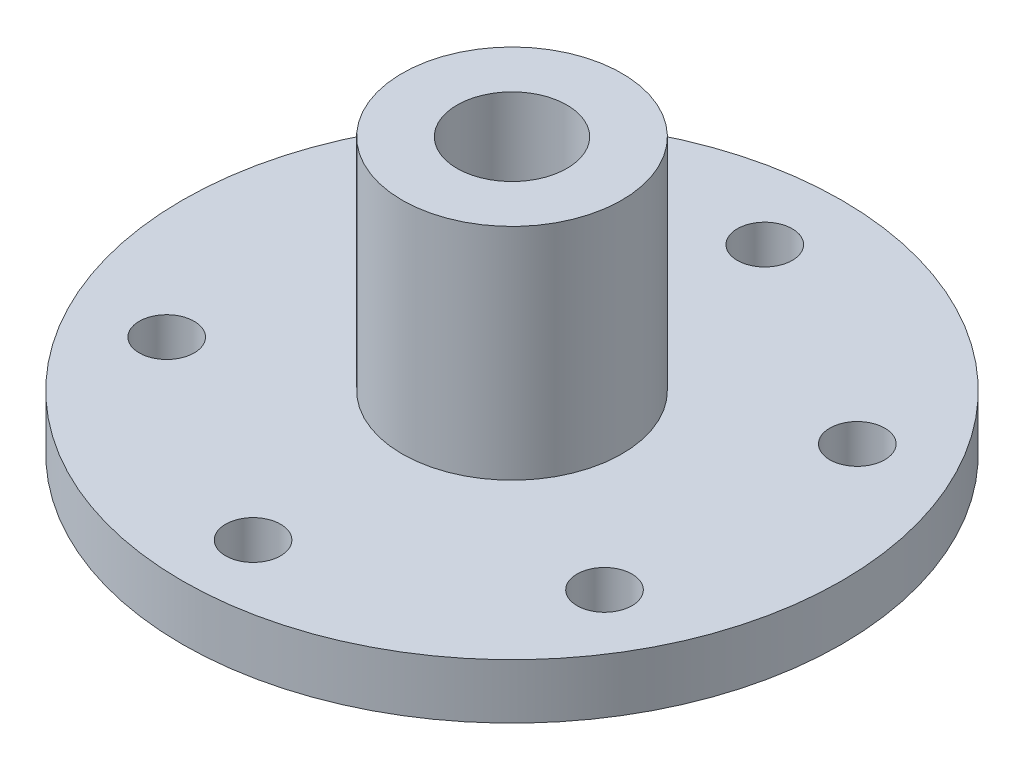
from build123d import *

# Parameters (mm, degrees)
SKETCH1_R           = 30
SKETCH1_R_2         = 2.5
BOSS_EXTRUDE2_DEPTH = 5
SKETCH2_R           = 10
BOSS_EXTRUDE3_DEPTH = 20
SKETCH3_R           = 5
CUT_EXTRUDE1_DEPTH  = 45


with BuildPart() as part:
    # Sketch1 → Boss-Extrude2 (new body)
    with BuildSketch(Plane(origin=(0, 0, 0), x_dir=(1, 0, 0), z_dir=(0, 1, 0))):
        Circle(SKETCH1_R)
        with Locations((0, 23)):
            Circle(SKETCH1_R_2, mode=Mode.SUBTRACT)
        with Locations((19.918584287, 11.5)):
            Circle(SKETCH1_R_2, mode=Mode.SUBTRACT)
        with Locations((19.918584287, -11.5)):
            Circle(SKETCH1_R_2, mode=Mode.SUBTRACT)
        with Locations((0, -23.561037846)):
            Circle(SKETCH1_R_2, mode=Mode.SUBTRACT)
        with Locations((-19.918584287, -11.5)):
            Circle(SKETCH1_R_2, mode=Mode.SUBTRACT)
        with Locations((-19.918584287, 11.5)):
            Circle(SKETCH1_R_2, mode=Mode.SUBTRACT)
    extrude(amount=BOSS_EXTRUDE2_DEPTH)

    # Sketch2 → Boss-Extrude3 (add)
    with BuildSketch(Plane(origin=(0, 5, 0), x_dir=(1, 0, 0), z_dir=(0, 1, 0))):
        Circle(SKETCH2_R)
    extrude(amount=BOSS_EXTRUDE3_DEPTH)

    # Sketch3 → Cut-Extrude1 (cut)
    with BuildSketch(Plane(origin=(0, 25, 0), x_dir=(1, 0, 0), z_dir=(0, 1, 0))):
        Circle(SKETCH3_R)
    extrude(amount=-CUT_EXTRUDE1_DEPTH, mode=Mode.SUBTRACT)


solid = part.part
